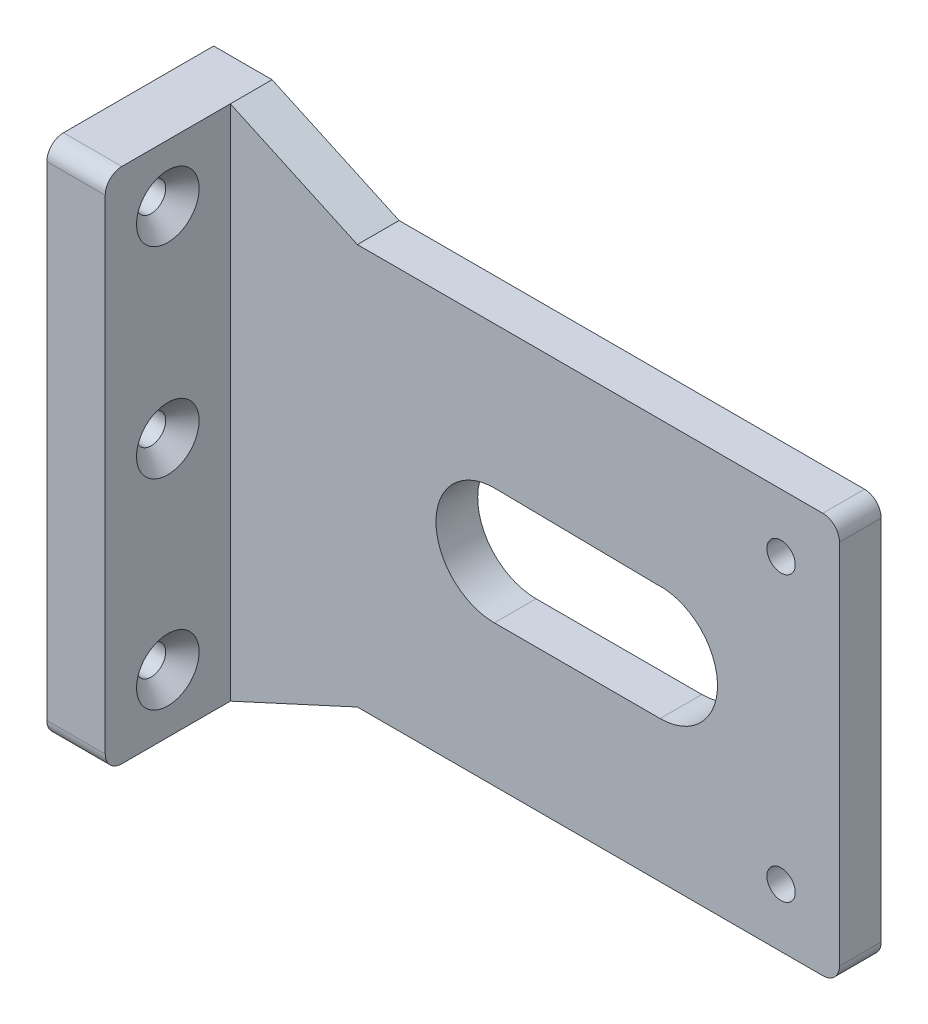
from build123d import *

# Parameters (mm, degrees)
SKETCH1_R           = 1.7
BOSS_EXTRUDE1_DEPTH = 5
SKETCH1_3_W         = 7
SKETCH1_3_H         = 62
BOSS_EXTRUDE2_DEPTH = 20
CUT_EXTRUDE1_DEPTH  = 18
CHAMFER1_SIZE       = 2
FILLET1_R           = 2


with BuildPart() as part:
    # Sketch1 → Boss-Extrude1 (new body)
    with BuildSketch(Plane.XY):
        Polygon((-85, 55), (-85, -7), (-78, -7), (-62.777714162, 0), (-5, 0), (-5, 48), (-62.777714162, 48), (-78, 55), align=None)
        with BuildLine():
            ThreePointArc((-46.360035435, 16.945547607), (-53.359341435, 24.044114973), (-46.162920248, 30.942771743))
            Line((-46.162920248, 30.942771743), (-27.013394309, 30.673099531))
            ThreePointArc((-27.013394309, 30.673099531), (-19.624563483, 24.079428786), (-26.493264539, 16.945547607))
            Line((-26.493264539, 16.945547607), (-46.360035435, 16.945547607))
        make_face(mode=Mode.SUBTRACT)
        with BuildLine():
            ThreePointArc((-13.7, 7), (-13.202081528, 8.202081528), (-12, 8.7))
            ThreePointArc((-12, 8.7), (-10.797918472, 5.797918472), (-13.7, 7))
        make_face(mode=Mode.SUBTRACT)
        with Locations((-12, 41)):
            Circle(SKETCH1_R, mode=Mode.SUBTRACT)
    extrude(amount=BOSS_EXTRUDE1_DEPTH)

    # Sketch1_3 → Boss-Extrude2 (add)
    with BuildSketch(Plane.XY):
        with Locations((-81.5, 24)):
            Rectangle(SKETCH1_3_W, SKETCH1_3_H)
    extrude(amount=BOSS_EXTRUDE2_DEPTH)

    # Sketch2 → Cut-Extrude1 (cut)
    with BuildSketch(Plane(origin=(-78, 0, 0), x_dir=(0, 0, -1), z_dir=(1, 0, 0))):
        with BuildLine():
            ThreePointArc((-12.5, 1.75), (-14.25, 0), (-12.5, -1.75))
            Line((-12.5, -1.75), (-12.5, 1.75))
        make_face()
        with BuildLine():
            Line((-12.5, 1.75), (-12.5, -1.75))
            ThreePointArc((-12.5, -1.75), (-11.262563133, -1.237436867), (-10.75, 0))
            ThreePointArc((-10.75, 0), (-11.262563133, 1.237436867), (-12.5, 1.75))
        make_face()
        with BuildLine():
            ThreePointArc((-12.5, 25.75), (-14.25, 24), (-12.5, 22.25))
            Line((-12.5, 22.25), (-12.5, 25.75))
        make_face()
        with BuildLine():
            Line((-12.5, 25.75), (-12.5, 22.25))
            ThreePointArc((-12.5, 22.25), (-11.262563133, 22.762563133), (-10.75, 24))
            ThreePointArc((-10.75, 24), (-11.262563133, 25.237436867), (-12.5, 25.75))
        make_face()
        with BuildLine():
            ThreePointArc((-12.5, 49.856077649), (-14.25, 48.106077649), (-12.5, 46.356077649))
            Line((-12.5, 46.356077649), (-12.5, 49.856077649))
        make_face()
        with BuildLine():
            Line((-12.5, 49.856077649), (-12.5, 46.356077649))
            ThreePointArc((-12.5, 46.356077649), (-11.262563133, 46.868640782), (-10.75, 48.106077649))
            ThreePointArc((-10.75, 48.106077649), (-11.262563133, 49.343514516), (-12.5, 49.856077649))
        make_face()
    extrude(amount=-CUT_EXTRUDE1_DEPTH, mode=Mode.SUBTRACT)

    # Chamfer1
    chamfer1_edges = [part.edges().sort_by_distance(p)[0] for p in [
        (-78, 1.75, 12.5),
        (-78, 25.75, 12.5),
        (-78, 49.856077649, 12.5),
    ]]
    chamfer(chamfer1_edges, length=CHAMFER1_SIZE)

    # Fillet1
    fillet1_edges = [part.edges().sort_by_distance(p)[0] for p in [
        (-5, 48, 2.5),
        (-5, 0, 2.5),
        (-81.5, -7, 20),
        (-81.5, 55, 20),
    ]]
    fillet(fillet1_edges, radius=FILLET1_R)


solid = part.part
